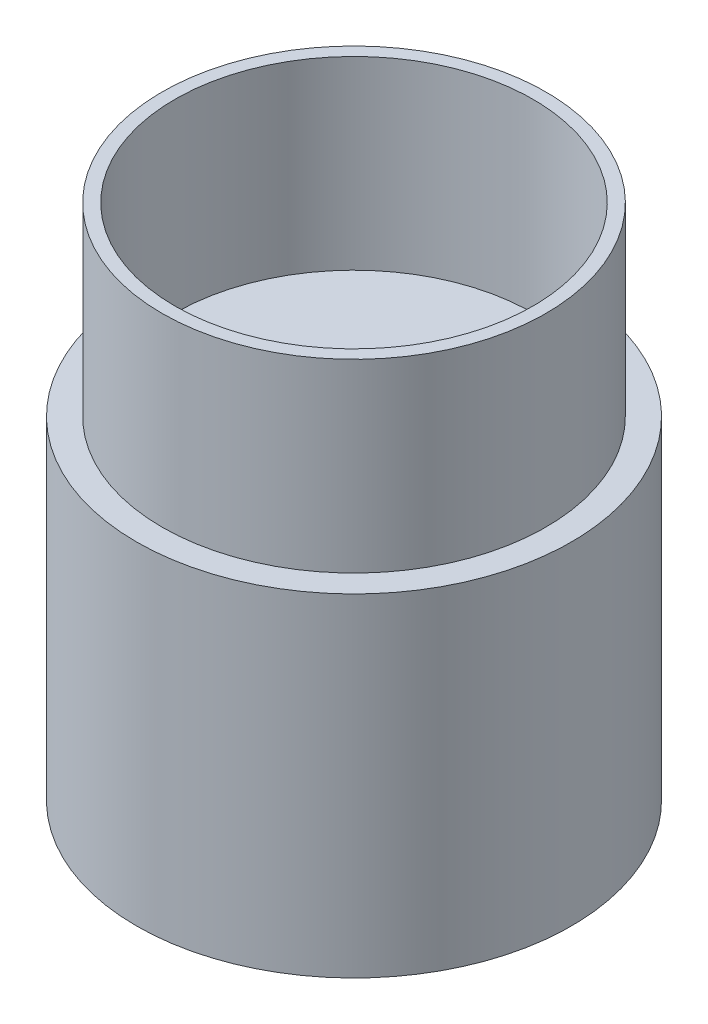
from build123d import *

# Parameters (mm, degrees)
SKETCH1_R           = 85
BOSS_EXTRUDE1_DEPTH = 130
SKETCH2_R           = 26
CUT_EXTRUDE1_DEPTH  = 124
SKETCH3_R           = 75
SKETCH3_R_2         = 70
BOSS_EXTRUDE2_DEPTH = 72.35


with BuildPart() as part:
    # Sketch1 → Boss-Extrude1 (new body)
    with BuildSketch(Plane(origin=(0, 0, 0), x_dir=(1, 0, 0), z_dir=(0, 1, 0))):
        Circle(SKETCH1_R)
    extrude(amount=BOSS_EXTRUDE1_DEPTH)

    # Sketch2 → Cut-Extrude1 (cut)
    with BuildSketch(Plane(origin=(0, 130, 0), x_dir=(1, 0, 0), z_dir=(0, 1, 0))):
        Circle(SKETCH2_R)
    extrude(amount=-CUT_EXTRUDE1_DEPTH, mode=Mode.SUBTRACT)

    # Sketch3 → Boss-Extrude2 (add)
    with BuildSketch(Plane(origin=(0, 130, 0), x_dir=(1, 0, 0), z_dir=(0, 1, 0))):
        Circle(SKETCH3_R)
        Circle(SKETCH3_R_2, mode=Mode.SUBTRACT)
    extrude(amount=BOSS_EXTRUDE2_DEPTH)


solid = part.part
